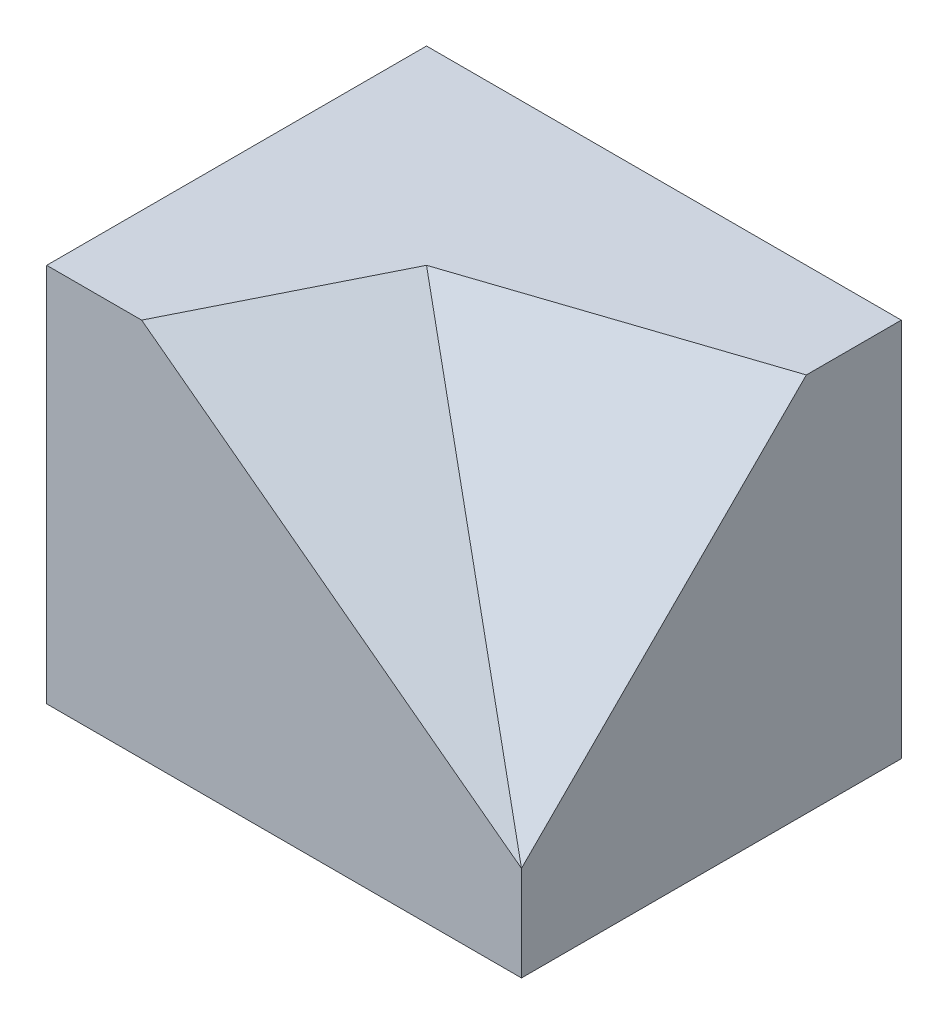
from build123d import *

# Parameters (mm, degrees)
SKETCH_1_W          = 25
SKETCH_1_H          = 20
EXTRUDE_1_DEPTH     = 20
CUT_EXTRUDE_1_DEPTH = 20
CUT_EXTRUDE_5_DEPTH = 20
SCALE_1_SCALE       = 0.2


with BuildPart() as part:
    # 草圖1 → 填料-伸長1 (new body)
    with BuildSketch(Plane(origin=(0, 0, 0), x_dir=(1, 0, 0), z_dir=(0, 1, 0))):
        Rectangle(SKETCH_1_W, SKETCH_1_H)
    extrude(amount=EXTRUDE_1_DEPTH)

    # 草圖5 → 除料-伸長1 (cut)
    with BuildSketch(Plane(origin=(7.981651376, 10.642201835, 3.990825688), x_dir=(-0.818367137, 0.538104419, 0.201789157), z_dir=(-0.574695771, -0.766261028, -0.287347886))):
        Polygon((-5.521175546, -7.607674568), (18.917733471, -2.340822944), (12.808006217, 7.022468832), align=None)
    extrude(amount=-CUT_EXTRUDE_1_DEPTH, mode=Mode.SUBTRACT)

    # 草圖7 → 除料-伸長5 (cut)
    with BuildSketch(Plane(origin=(3.026315789, 9.078947368, 9.078947368), x_dir=(0.973328527, -0.162221421, -0.162221421), z_dir=(0.229415734, 0.688247202, 0.688247202))):
        Polygon((9.733285268, -3.535533906), (9.733285268, 17.67766953), (-5.67774974, 14.142135624), align=None)
    extrude(amount=CUT_EXTRUDE_5_DEPTH, mode=Mode.SUBTRACT)


with BuildPart() as part_1:
    # 縮放比例1: scaled about (-0.76048951, 9.256993007, -0.655594406)
    add(part.part.scale(SCALE_1_SCALE).moved(Location((-0.608391608, 7.405594406, -0.524475525))))


solid = part_1.part
